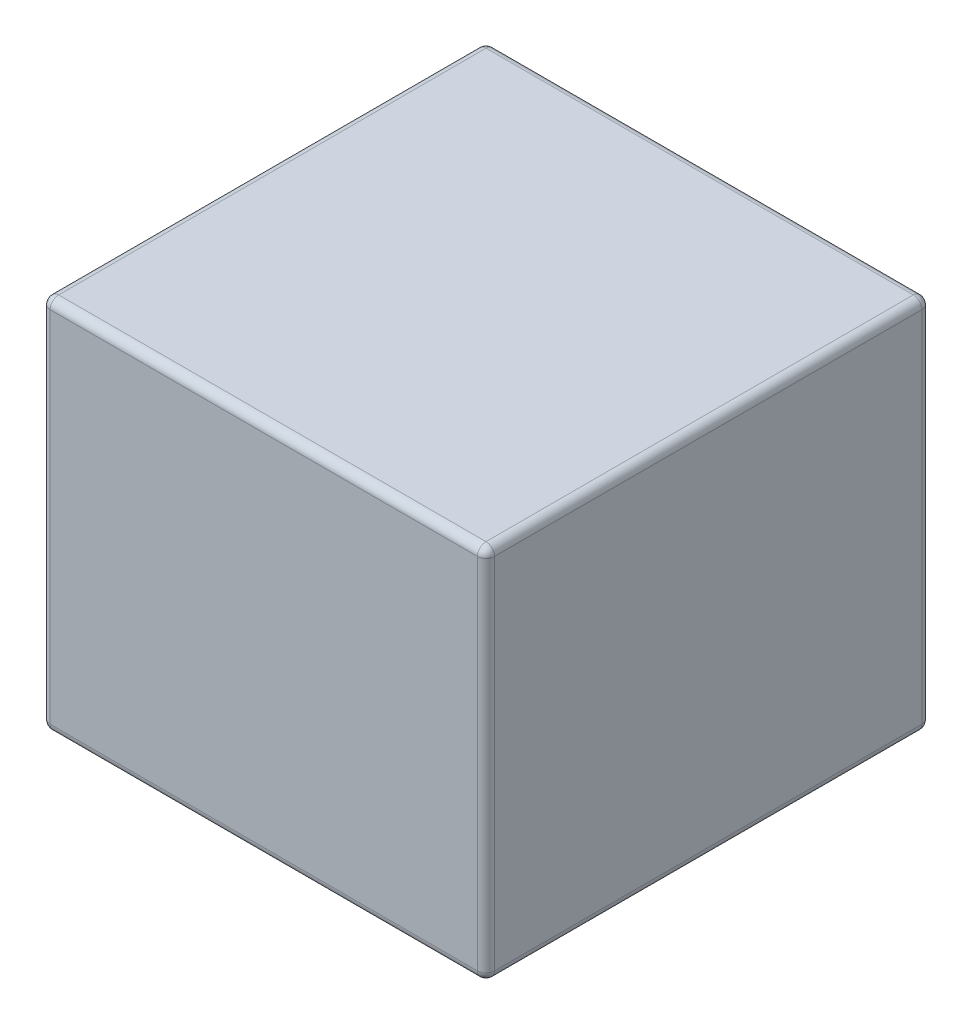
from build123d import *

# Parameters (mm, degrees)
SKETCH1_W           = 330.2
SKETCH1_H           = 330.2
BOSS_EXTRUDE1_DEPTH = 279.4
FILLET1_R           = 6.35


with BuildPart() as part:
    # Sketch1 → Boss-Extrude1 (new body)
    with BuildSketch(Plane(origin=(0, 0, 0), x_dir=(1, 0, 0), z_dir=(0, 1, 0))):
        with Locations((165.1, 165.1)):
            Rectangle(SKETCH1_W, SKETCH1_H)
    extrude(amount=BOSS_EXTRUDE1_DEPTH)

    # Fillet1
    fillet1_edges = [part.edges().sort_by_distance(p)[0] for p in [
        (330.2, 279.4, -165.1),
        (165.1, 279.4, -330.2),
        (0, 279.4, -165.1),
        (165.1, 0, -330.2),
        (330.2, 0, -165.1),
        (165.1, 0, 0),
        (0, 0, -165.1),
        (165.1, 279.4, 0),
        (0, 139.7, -330.2),
        (330.2, 139.7, -330.2),
        (330.2, 139.7, 0),
        (0, 139.7, 0),
    ]]
    fillet(fillet1_edges, radius=FILLET1_R)


solid = part.part
